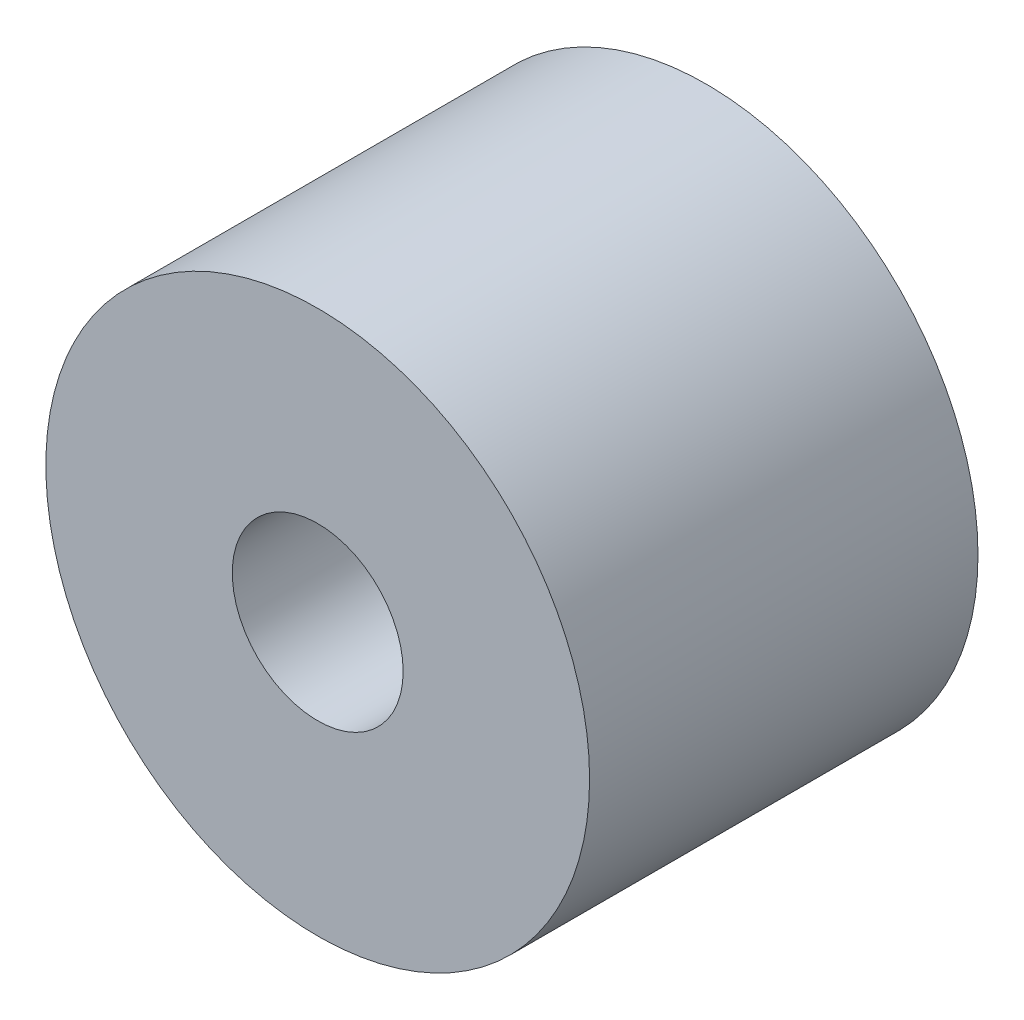
from build123d import *

# Parameters (mm, degrees)
ESQUISSE1_R        = 3.5
ESQUISSE1_R_2      = 1.1
BOSS_EXTRU_1_DEPTH = 5


with BuildPart() as part:
    # Esquisse1 → Boss.-Extru.1 (new body)
    with BuildSketch(Plane.XY):
        Circle(ESQUISSE1_R)
        Circle(ESQUISSE1_R_2, mode=Mode.SUBTRACT)
    extrude(amount=BOSS_EXTRU_1_DEPTH)


solid = part.part
